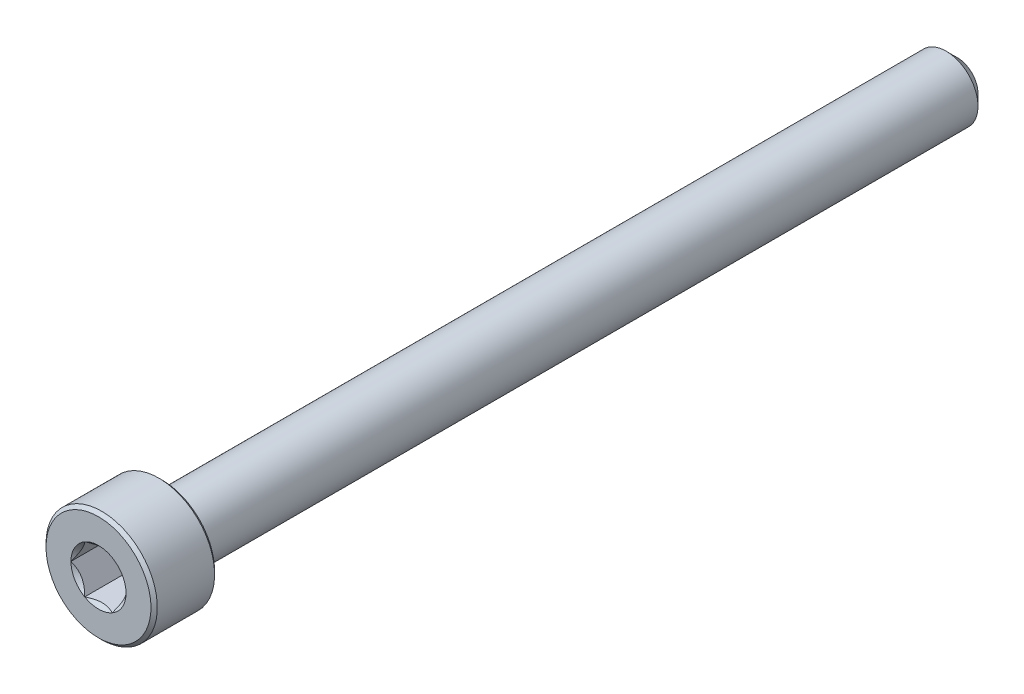
from build123d import *

# Parameters (mm, degrees)
CUT_EXTRUDE1_DEPTH = 3
SKETCH4_R          = 1.732050808
CUT_EXTRUDE2_DEPTH = 3
CUT_EXTRUDE2_DRAFT = -45


with BuildPart() as part:
    # Sketch2 → Revolve1 (revolve)
    with BuildSketch(Plane(origin=(0, 0, 0), x_dir=(0, 0, -1), z_dir=(1, 0, 0))):
        Polygon((-27, 0), (-27, 3.3), (-26.8, 3.5), (-23.2, 3.5), (-23, 3.3), (-23, 2), (26.3, 2), (27, 1.3), (27, 0), align=None)
    revolve(axis=Axis((0, 0, -27), (0, 0, 1)))

    # Sketch3 → Cut-Extrude1 (cut)
    with BuildSketch(Plane.XY.offset(27)):
        Polygon((0.866025404, 1.5), (-0.866025404, 1.5), (-1.732050808, 0), (-0.866025404, -1.5), (0.866025404, -1.5), (1.732050808, 0), align=None)
    extrude(amount=-CUT_EXTRUDE1_DEPTH, mode=Mode.SUBTRACT)


with BuildPart() as cut_extrude2_tool:
    # Sketch4 → Cut-Extrude2 (with draft: the straight prism first)
    with BuildSketch(Plane.XY.offset(27)):
        Circle(SKETCH4_R)
    extrude(amount=-CUT_EXTRUDE2_DEPTH)
    # Cut-Extrude2: the draft: its side faces are tilted about the plane it starts from
    cut_extrude2_sides = [cut_extrude2_tool.faces().sort_by_distance(p)[0] for p in [
        (-1.732050808, 0, 25.5),
    ]]
    draft(cut_extrude2_sides, Plane.XY.offset(27), CUT_EXTRUDE2_DRAFT)


with BuildPart() as part_1:
    add(part.part)

    # Cut-Extrude2: cut by cut_extrude2_tool
    add(cut_extrude2_tool.part, mode=Mode.SUBTRACT)


solid = part_1.part
